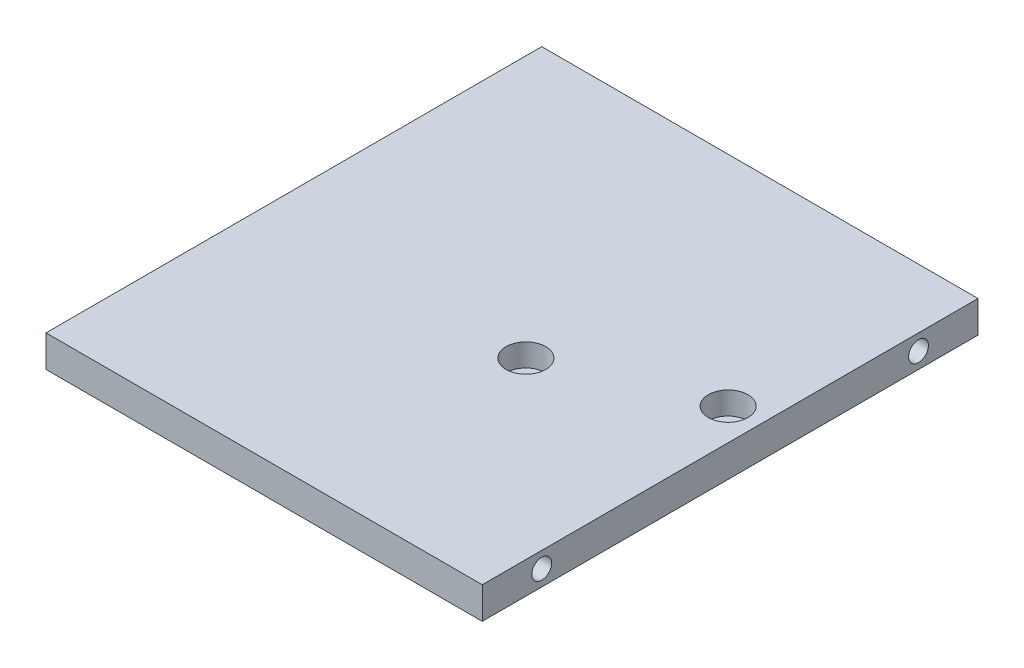
from build123d import *

# Parameters (mm, degrees)
SKETCH1_W           = 110
SKETCH1_H           = 125
BOSS_EXTRUDE2_DEPTH = 8
SKETCH2_R           = 2.75
CUT_EXTRUDE1_DEPTH  = 8
SKETCH3_R           = 2.5
CUT_EXTRUDE2_DEPTH  = 15
SKETCH4_R           = 2.5
CUT_EXTRUDE3_DEPTH  = 15
SKETCH5_R           = 5
CUT_EXTRUDE4_DEPTH  = 5.7


with BuildPart() as part:
    # Sketch1 → Boss-Extrude2 (new body)
    with BuildSketch(Plane(origin=(0, 0, 0), x_dir=(1, 0, 0), z_dir=(0, 1, 0))):
        Rectangle(SKETCH1_W, SKETCH1_H)
    extrude(amount=BOSS_EXTRUDE2_DEPTH)

    # Sketch2 → Cut-Extrude1 (cut)
    with BuildSketch(Plane(origin=(0, 8, 0), x_dir=(1, 0, 0), z_dir=(0, 1, 0))):
        with Locations((47, 7.5)):
            Circle(SKETCH2_R)
        with Locations((11, -7.5)):
            Circle(SKETCH2_R)
    extrude(amount=-CUT_EXTRUDE1_DEPTH, mode=Mode.SUBTRACT)

    # Sketch3 → Cut-Extrude2 (cut)
    with BuildSketch(Plane.ZY.offset(55)):
        with Locations((47.5, 4)):
            Circle(SKETCH3_R)
        with Locations((-47.5, 4)):
            Circle(SKETCH3_R)
    extrude(amount=-CUT_EXTRUDE2_DEPTH, mode=Mode.SUBTRACT)

    # Sketch4 → Cut-Extrude3 (cut)
    with BuildSketch(Plane(origin=(55, 0, 0), x_dir=(0, 0, -1), z_dir=(1, 0, 0))):
        with Locations((47.5, 4)):
            Circle(SKETCH4_R)
        with Locations((-47.5, 4)):
            Circle(SKETCH4_R)
    extrude(amount=-CUT_EXTRUDE3_DEPTH, mode=Mode.SUBTRACT)

    # Sketch5 → Cut-Extrude4 (cut)
    with BuildSketch(Plane(origin=(0, 8, 0), x_dir=(1, 0, 0), z_dir=(0, 1, 0))):
        with Locations((11, -7.5)):
            Circle(SKETCH5_R)
        with Locations((47, 7.5)):
            Circle(SKETCH5_R)
    extrude(amount=-CUT_EXTRUDE4_DEPTH, mode=Mode.SUBTRACT)


solid = part.part
